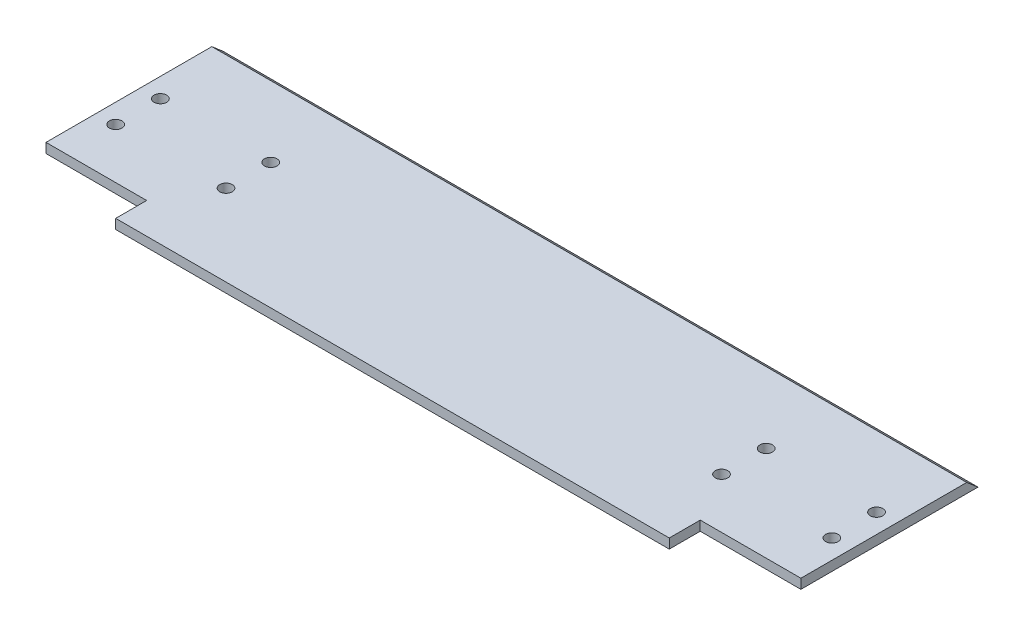
from build123d import *

# Parameters (mm, degrees)
CROQUIS1_R              = 1.625
CUERPO_INICIAL_DEPTH    = 2.5
SALIENTE_EXTRUIR2_DEPTH = 195
CROQUIS6_W              = 143
CROQUIS6_H              = 28
CORTAR_EXTRUIR1_DEPTH   = 10


with BuildPart() as part:
    # Croquis1 → Cuerpo Inicial (new body)
    with BuildSketch(Plane(origin=(0, 0, 0), x_dir=(1, 0, 0), z_dir=(0, 1, 0))):
        Polygon((-71.5, -25), (-71.5, -61), (71.5, -61), (71.5, -25), (97.5, -25), (97.5, 0), (97.5, 1), (97.5, 5.7), (45, 5.7), (-45, 5.7), (-97.5, 5.7), (-97.5, 1), (-97.5, 0), (-97.5, -25), align=None)
        with Locations((-92.5, -12)):
            Circle(CROQUIS1_R, mode=Mode.SUBTRACT)
        with Locations((-64, -12)):
            Circle(CROQUIS1_R, mode=Mode.SUBTRACT)
        with Locations((-92.5, -0.46)):
            Circle(CROQUIS1_R, mode=Mode.SUBTRACT)
        with Locations((-64, -0.46)):
            Circle(CROQUIS1_R, mode=Mode.SUBTRACT)
        with Locations((64, -12)):
            Circle(CROQUIS1_R, mode=Mode.SUBTRACT)
        with Locations((92.5, -12)):
            Circle(CROQUIS1_R, mode=Mode.SUBTRACT)
        with Locations((64, -0.46)):
            Circle(CROQUIS1_R, mode=Mode.SUBTRACT)
        with Locations((92.5, -0.46)):
            Circle(CROQUIS1_R, mode=Mode.SUBTRACT)
    extrude(amount=CUERPO_INICIAL_DEPTH)

    # Croquis3 → Saliente-Extruir2 (add)
    with BuildSketch(Plane(origin=(97.5, 0, 0), x_dir=(0, 0, -1), z_dir=(1, 0, 0))):
        Polygon((5.7, 2.5), (17.833199952, 2.5), (20.75, 0), (5.7, 0), align=None)
    extrude(amount=-SALIENTE_EXTRUIR2_DEPTH)

    # Croquis6 → Cortar-Extruir1 (cut)
    with BuildSketch(Plane(origin=(0, 2.5, 0), x_dir=(1, 0, 0), z_dir=(0, 1, 0))):
        with Locations((0, -47)):
            Rectangle(CROQUIS6_W, CROQUIS6_H)
    extrude(amount=-CORTAR_EXTRUIR1_DEPTH, mode=Mode.SUBTRACT)


solid = part.part
